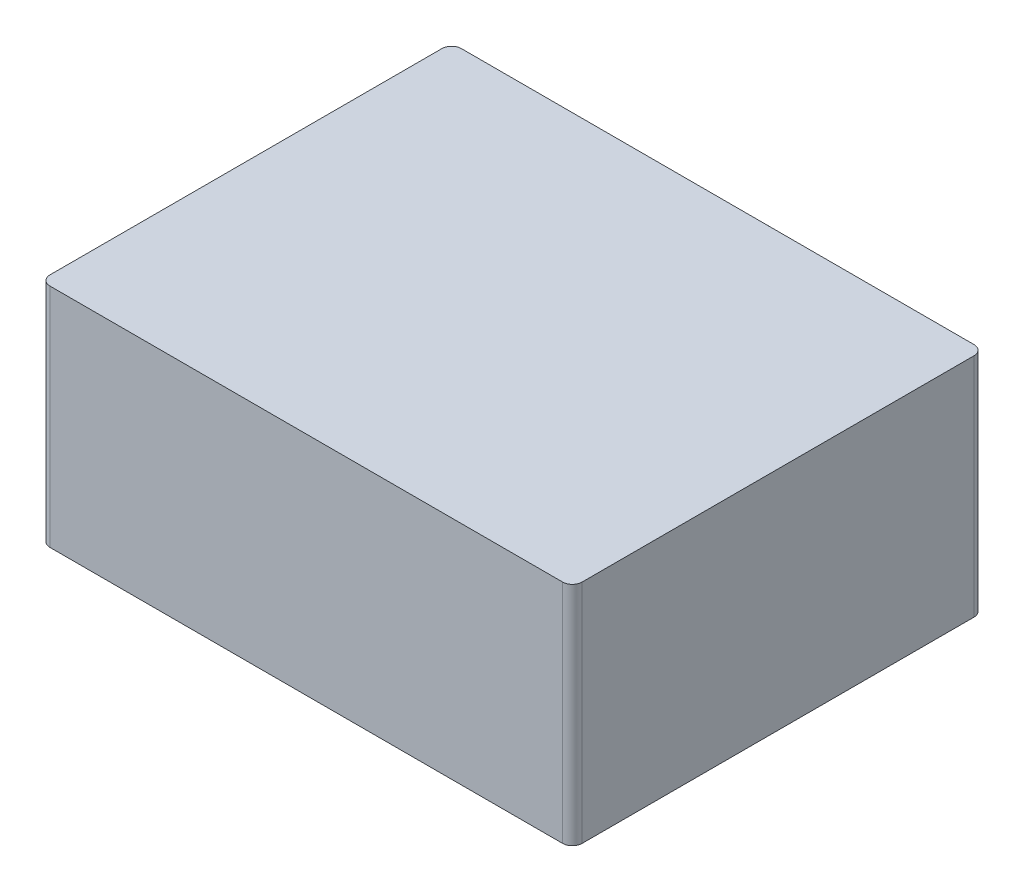
from build123d import *

# Parameters (mm, degrees)
SKETCH1_W           = 109.3
SKETCH1_H           = 84.5
BOSS_EXTRUDE3_DEPTH = 46.5
FILLET2_R           = 2
FILLET3_R           = 2
FILLET4_R           = 2
FILLET5_R           = 2


with BuildPart() as part:
    # Sketch1 → Boss-Extrude3 (new body)
    with BuildSketch(Plane(origin=(0, 0, 0), x_dir=(1, 0, 0), z_dir=(0, 1, 0))):
        with Locations((54.65, 42.25)):
            Rectangle(SKETCH1_W, SKETCH1_H)
    extrude(amount=BOSS_EXTRUDE3_DEPTH)

    # Fillet2
    fillet2_edges = [part.edges().sort_by_distance(p)[0] for p in [
        (109.3, 23.25, 0),
    ]]
    fillet(fillet2_edges, radius=FILLET2_R)

    # Fillet3
    fillet3_edges = [part.edges().sort_by_distance(p)[0] for p in [
        (0, 23.25, 0),
    ]]
    fillet(fillet3_edges, radius=FILLET3_R)

    # Fillet4
    fillet4_edges = [part.edges().sort_by_distance(p)[0] for p in [
        (109.3, 23.25, -84.5),
    ]]
    fillet(fillet4_edges, radius=FILLET4_R)

    # Fillet5
    fillet5_edges = [part.edges().sort_by_distance(p)[0] for p in [
        (0, 23.25, -84.5),
    ]]
    fillet(fillet5_edges, radius=FILLET5_R)


solid = part.part
